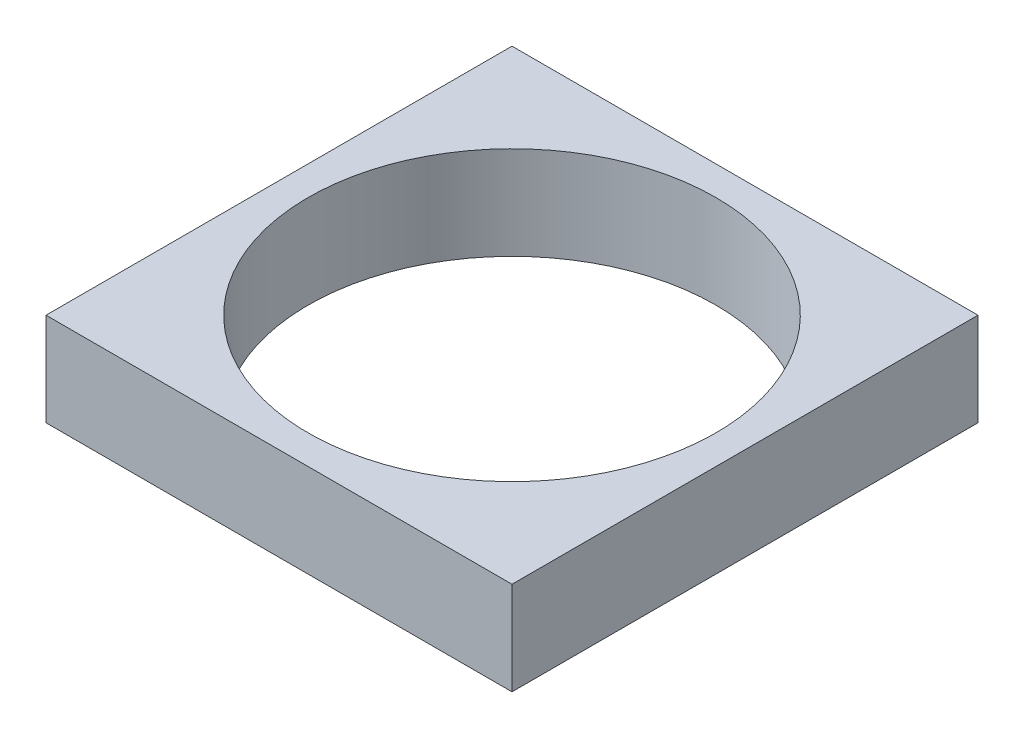
from build123d import *

# Parameters (mm, degrees)
SKETCH1_W           = 80
SKETCH1_H           = 80
BOSS_EXTRUDE1_DEPTH = 16
SKETCH2_R           = 35
CUT_EXTRUDE1_DEPTH  = 17


with BuildPart() as part:
    # Sketch1 → Boss-Extrude1 (new body)
    with BuildSketch(Plane(origin=(0, 0, 0), x_dir=(1, 0, 0), z_dir=(0, 1, 0))):
        Rectangle(SKETCH1_W, SKETCH1_H)
    extrude(amount=BOSS_EXTRUDE1_DEPTH)

    # Sketch2 → Cut-Extrude1 (cut, through all)
    with BuildSketch(Plane.XZ):
        Circle(SKETCH2_R)
    extrude(amount=-CUT_EXTRUDE1_DEPTH, mode=Mode.SUBTRACT)


solid = part.part
